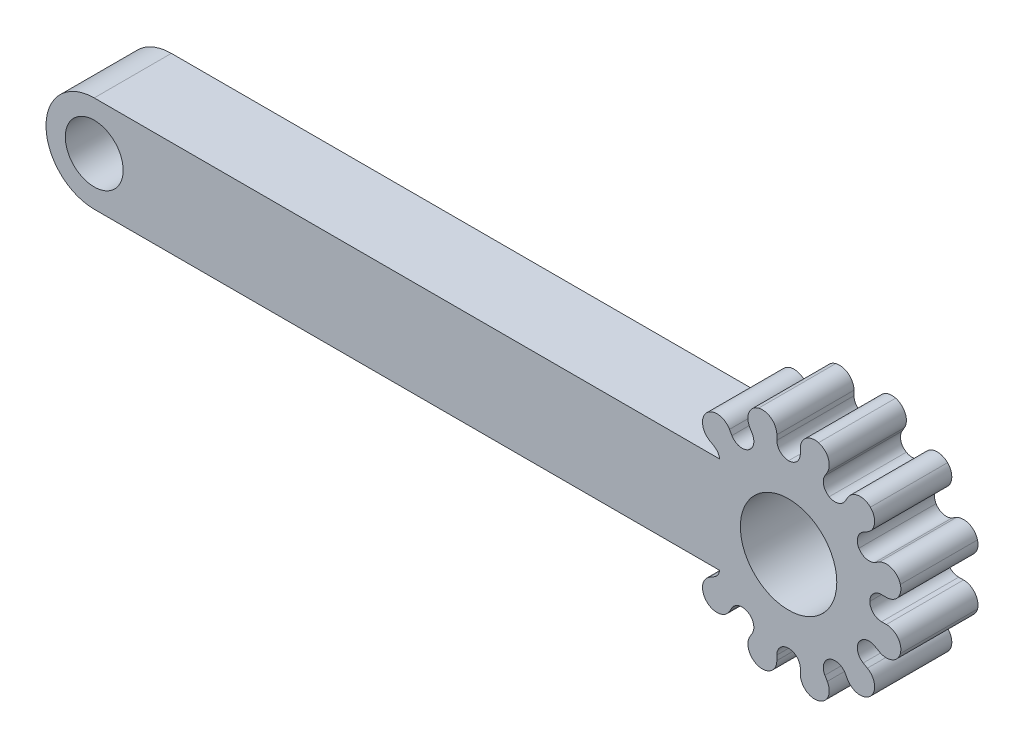
from build123d import *

# Parameters (mm, degrees)
SKETCH1_R           = 1.5
BOSS_EXTRUDE1_DEPTH = 4
CUT_EXTRUDE2_DEPTH  = 5
CIRPATTERN1_COUNT   = 12
SKETCH3_W           = 7.863082298
SKETCH3_H           = 5
BOSS_EXTRUDE2_DEPTH = 4
SKETCH4_R           = 2.5
CUT_EXTRUDE3_DEPTH  = 5


with BuildPart() as part:
    # Sketch1 → Boss-Extrude1 (new body)
    with BuildSketch(Plane.XY):
        with BuildLine():
            Line((-18, 2.5), (12.545643943, 2.5))
            ThreePointArc((12.545643943, 2.5), (24, 0), (12.545643943, -2.5))
            Line((12.545643943, -2.5), (-18, -2.5))
            ThreePointArc((-18, -2.5), (-20.5, 0), (-18, 2.5))
        make_face()
        with Locations((-18, 0)):
            Circle(SKETCH1_R, mode=Mode.SUBTRACT)
    extrude(amount=BOSS_EXTRUDE1_DEPTH)

    # Sketch2 → Cut-Extrude2 (cut, through all)
    with BuildSketch(Plane.XY.offset(4)):
        with BuildLine():
            Line((20.008070513, 4.695554958), (19.882890915, 4.479152397))
            ThreePointArc((19.882890915, 4.479152397), (19.821496871, 4.016588638), (20.105, 3.64596695))
            ThreePointArc((20.105, 3.64596695), (20.567719361, 3.585756883), (20.937614306, 3.870207564))
            Line((20.937614306, 3.870207564), (21.062434622, 4.086817556))
            ThreePointArc((21.062434622, 4.086817556), (21.614093727, 4.455903836), (22.242640687, 4.242640687))
            ThreePointArc((22.242640687, 4.242640687), (21.17938524, 5.506856773), (19.552914271, 5.795554958))
            ThreePointArc((19.552914271, 5.795554958), (20.051879055, 5.357848898), (20.008070513, 4.695554958))
        make_face()
    cut_extrude2 = extrude(amount=-CUT_EXTRUDE2_DEPTH, mode=Mode.SUBTRACT)

    # CirPattern1: Cut-Extrude2 ×12 about axis
    cirpattern1_axis = Axis((18, 0, 0), (0, 0, 1))
    for i in range(1, CIRPATTERN1_COUNT):
        add(cut_extrude2.rotate(cirpattern1_axis, i * 360 / CIRPATTERN1_COUNT), mode=Mode.SUBTRACT)

    # Sketch3 → Boss-Extrude2 (add)
    with BuildSketch(Plane.XY.offset(4)):
        with Locations((12.029323846, 0)):
            Rectangle(SKETCH3_W, SKETCH3_H)
    extrude(amount=-BOSS_EXTRUDE2_DEPTH)

    # Sketch4 → Cut-Extrude3 (cut, through all)
    with BuildSketch(Plane.XY.offset(4)):
        with Locations((18, 0)):
            Circle(SKETCH4_R)
    extrude(amount=-CUT_EXTRUDE3_DEPTH, mode=Mode.SUBTRACT)


solid = part.part
